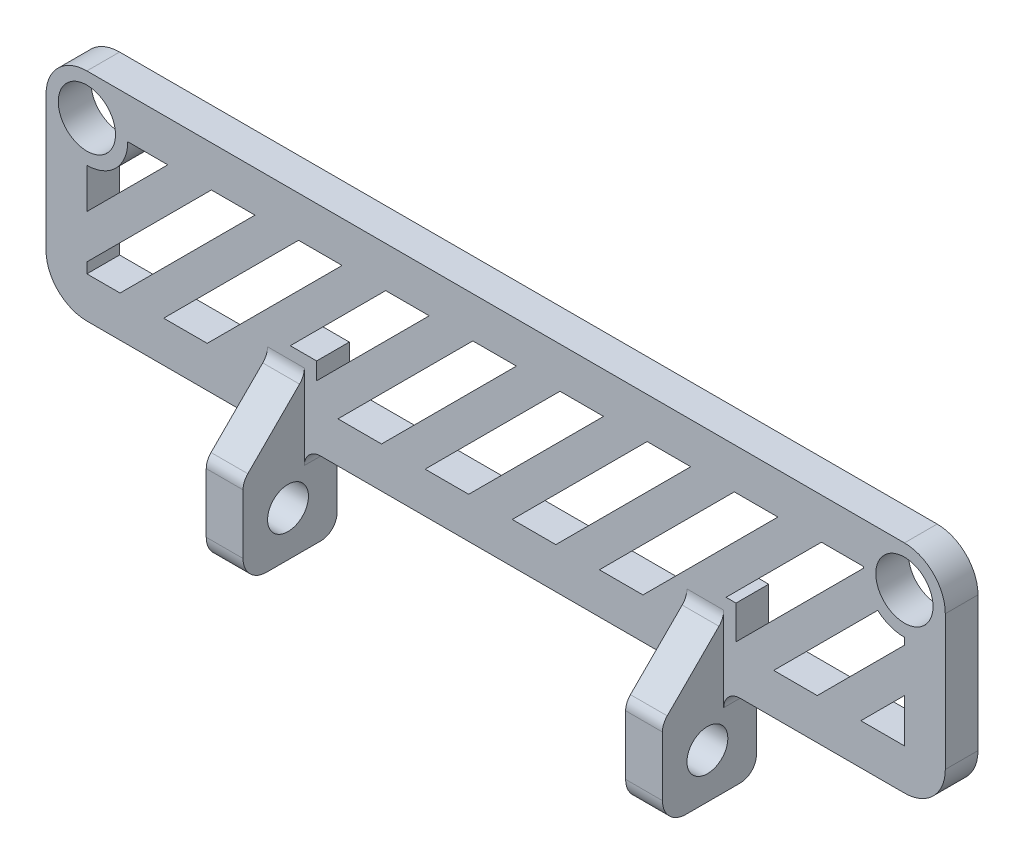
from build123d import *

# Parameters (mm, degrees)
ESQUISSE1_R             = 1.75
BOSS_EXTRU_1_DEPTH      = 2
ESQUISSE1_3_W           = 2.25
ESQUISSE1_3_H           = 5.5
BOSS_EXTRU_3_DEPTH      = 5.75
ENL_V_MAT_EXTRU_4_REACH = 44.884
ESQUISSE2_W             = 5.75
ESQUISSE2_H             = 5.5
ENL_V_MAT_EXTRU_5_REACH = 44.884
ESQUISSE2_5_R           = 1.25
NERVURE1_REACH          = 44.884
ESQUISSE4_WALL_W        = 93.071724536
ESQUISSE4_WALL_H        = 2.25
CONG_1_R                = 1.45
CONG_2_R                = 1
ENL_V_MAT_EXTRU_6_REACH = 31.295
CONG_4_R                = 2.5


with BuildPart() as part:
    # Esquisse1 → Boss.-Extru.1 (new body)
    with BuildSketch(Plane.XY):
        Polygon((27.5, 9.375), (-27.5, 9.375), (-27.5, -9.375), (-13.95, -9.375), (-13.95, -3.875), (-11.7, -3.875), (11.7, -3.875), (13.95, -3.875), (13.95, -9.375), (27.5, -9.375), align=None)
        with Locations((-25, 6.875)):
            Circle(ESQUISSE1_R, mode=Mode.SUBTRACT)
        with Locations((25, 6.875)):
            Circle(ESQUISSE1_R, mode=Mode.SUBTRACT)
    extrude(amount=BOSS_EXTRU_1_DEPTH)

    # Esquisse1_3 → Boss.-Extru.3 (add)
    with BuildSketch(Plane.XY):
        with Locations((-12.825, -6.625)):
            Rectangle(ESQUISSE1_3_W, ESQUISSE1_3_H)
        with Locations((12.825, -6.625)):
            Rectangle(ESQUISSE1_3_W, ESQUISSE1_3_H)
    extrude(amount=BOSS_EXTRU_3_DEPTH)

    # Esquisse2 → Enl_v. mat.-Extru.4 (cut, up to next)
    with BuildSketch(Plane(origin=(13.95, 0, 0), x_dir=(0, 0, -1), z_dir=(1, 0, 0)), mode=Mode.PRIVATE) as enl_v_mat_extru_4_sk1:
        with Locations((-2.875, -6.625)):
            Rectangle(ESQUISSE2_W, ESQUISSE2_H)
    enl_v_mat_extru_4_tool1 = extrude(enl_v_mat_extru_4_sk1.sketch, amount=ENL_V_MAT_EXTRU_4_REACH, mode=Mode.PRIVATE) & part.part
    enl_v_mat_extru_4 = enl_v_mat_extru_4_tool1.solids().sort_by_distance((13.95, -6.625, 2.875))[0]
    add(enl_v_mat_extru_4, mode=Mode.SUBTRACT)

    # Esquisse2_5 → Enl_v. mat.-Extru.5 (cut, up to next)
    with BuildSketch(Plane(origin=(13.95, 0, 0), x_dir=(0, 0, -1), z_dir=(1, 0, 0)), mode=Mode.PRIVATE) as enl_v_mat_extru_5_sk1:
        with Locations((-3, -6.625)):
            Circle(ESQUISSE2_5_R)
    enl_v_mat_extru_5_tool1 = extrude(enl_v_mat_extru_5_sk1.sketch, amount=-ENL_V_MAT_EXTRU_5_REACH, mode=Mode.PRIVATE) & part.part
    enl_v_mat_extru_5 = enl_v_mat_extru_5_tool1.solids().sort_by_distance((13.95, -6.625, 3))[0]
    add(enl_v_mat_extru_5, mode=Mode.SUBTRACT)

    # Esquisse4 wall → Nervure1 (add, up to next)
    with BuildSketch(Plane(origin=(13.95, -2, 3.875), x_dir=(0, 0.707106781187, -0.707106781187), z_dir=(0, 0.707106781187, 0.707106781187)), mode=Mode.PRIVATE) as nervure1_sk1:
        with Locations((0, 1.125)):
            Rectangle(ESQUISSE4_WALL_W, ESQUISSE4_WALL_H)
    nervure1_tool1 = extrude(nervure1_sk1.sketch, amount=-NERVURE1_REACH, mode=Mode.PRIVATE) - part.part
    nervure1 = nervure1_tool1.solids().sort_by_distance((13.95, -2, 3.875))[0]
    add(nervure1)

    # Sym_trie2: Enl_v. mat.-Extru.4, Enl_v. mat.-Extru.5, Nervure1 across plane
    add(enl_v_mat_extru_4.mirror(Plane(origin=(0, 0, 0), x_dir=(0, 0, 1), z_dir=(1, 0, 0))), mode=Mode.SUBTRACT)
    add(enl_v_mat_extru_5.mirror(Plane(origin=(0, 0, 0), x_dir=(0, 0, 1), z_dir=(1, 0, 0))), mode=Mode.SUBTRACT)
    add(nervure1.mirror(Plane(origin=(0, 0, 0), x_dir=(0, 0, 1), z_dir=(1, 0, 0))))

    # Cong_1
    cong_1_edges = [part.edges().sort_by_distance(p)[0] for p in [
        (12.825, -9.375, 5.75),
        (-12.825, -9.375, 5.75),
    ]]
    fillet(cong_1_edges, radius=CONG_1_R)

    # Cong_2
    cong_2_edges = [part.edges().sort_by_distance(p)[0] for p in [
        (12.825, -0.125, 2),
        (12.825, -3.875, 5.75),
        (13.95, -3.875, 1),
        (11.7, -3.875, 1),
        (12.825, -9.375, 0),
        (-12.825, -9.375, 0),
        (-13.95, -3.875, 1),
        (-11.7, -3.875, 1),
        (-12.825, -0.125, 2),
        (-12.825, -3.875, 5.75),
    ]]
    fillet(cong_2_edges, radius=CONG_2_R)

    # Esquisse5 → Enl_v. mat.-Extru.6 (cut, up to next)
    with BuildSketch(Plane.XY.offset(2), mode=Mode.PRIVATE) as enl_v_mat_extru_6_sk1:
        with BuildLine():
            Line((-20.050252532, 6.875), (-22.5, 6.875))
            ThreePointArc((-22.5, 6.875), (-23.232233047, 5.107233047), (-25, 4.375))
            Line((-25, 4.375), (-25, 1.925252532))
            Line((-25, 1.925252532), (-20.050252532, 6.875))
        make_face()
    enl_v_mat_extru_6_tool1 = extrude(enl_v_mat_extru_6_sk1.sketch, amount=-ENL_V_MAT_EXTRU_6_REACH, mode=Mode.PRIVATE) & part.part
    # Esquisse5 → Enl_v. mat.-Extru.6 (cut, up to next)
    with BuildSketch(Plane.XY.offset(2), mode=Mode.PRIVATE) as enl_v_mat_extru_6_sk2:
        Polygon((-14.720227279, 6.875), (-17.385239905, 6.875), (-25, -0.739760095), (-25, -1.375), (-22.970227279, -1.375), align=None)
    enl_v_mat_extru_6_tool2 = extrude(enl_v_mat_extru_6_sk2.sketch, amount=-ENL_V_MAT_EXTRU_6_REACH, mode=Mode.PRIVATE) & part.part
    # Esquisse5 → Enl_v. mat.-Extru.6 (cut, up to next)
    with BuildSketch(Plane.XY.offset(2), mode=Mode.PRIVATE) as enl_v_mat_extru_6_sk3:
        Polygon((-9.390202025, 6.875), (-12.055214652, 6.875), (-20.305214652, -1.375), (-17.640202025, -1.375), align=None)
    enl_v_mat_extru_6_tool3 = extrude(enl_v_mat_extru_6_sk3.sketch, amount=-ENL_V_MAT_EXTRU_6_REACH, mode=Mode.PRIVATE) & part.part
    # Esquisse5 → Enl_v. mat.-Extru.6 (cut, up to next)
    with BuildSketch(Plane.XY.offset(2), mode=Mode.PRIVATE) as enl_v_mat_extru_6_sk4:
        Polygon((-4.060176772, 6.875), (-6.725189399, 6.875), (-12.560975836, 1.039213562), (-10.95, 1.039213562), (-10.95, -0.014823228), align=None)
    enl_v_mat_extru_6_tool4 = extrude(enl_v_mat_extru_6_sk4.sketch, amount=-ENL_V_MAT_EXTRU_6_REACH, mode=Mode.PRIVATE) & part.part
    # Esquisse5 → Enl_v. mat.-Extru.6 (cut, up to next)
    with BuildSketch(Plane.XY.offset(2), mode=Mode.PRIVATE) as enl_v_mat_extru_6_sk5:
        Polygon((1.269848481, 6.875), (-1.395164146, 6.875), (-9.645164146, -1.375), (-6.980151519, -1.375), align=None)
    enl_v_mat_extru_6_tool5 = extrude(enl_v_mat_extru_6_sk5.sketch, amount=-ENL_V_MAT_EXTRU_6_REACH, mode=Mode.PRIVATE) & part.part
    # Esquisse5 → Enl_v. mat.-Extru.6 (cut, up to next)
    with BuildSketch(Plane.XY.offset(2), mode=Mode.PRIVATE) as enl_v_mat_extru_6_sk6:
        Polygon((6.599873734, 6.875), (3.934861108, 6.875), (-4.315138892, -1.375), (-1.650126266, -1.375), align=None)
    enl_v_mat_extru_6_tool6 = extrude(enl_v_mat_extru_6_sk6.sketch, amount=-ENL_V_MAT_EXTRU_6_REACH, mode=Mode.PRIVATE) & part.part
    # Esquisse5 → Enl_v. mat.-Extru.6 (cut, up to next)
    with BuildSketch(Plane.XY.offset(2), mode=Mode.PRIVATE) as enl_v_mat_extru_6_sk7:
        Polygon((11.929898987, 6.875), (9.264886361, 6.875), (1.014886361, -1.375), (3.679898987, -1.375), align=None)
    enl_v_mat_extru_6_tool7 = extrude(enl_v_mat_extru_6_sk7.sketch, amount=-ENL_V_MAT_EXTRU_6_REACH, mode=Mode.PRIVATE) & part.part
    # Esquisse5 → Enl_v. mat.-Extru.6 (cut, up to next)
    with BuildSketch(Plane.XY.offset(2), mode=Mode.PRIVATE) as enl_v_mat_extru_6_sk8:
        Polygon((17.25992424, 6.875), (14.594911614, 6.875), (6.344911614, -1.375), (9.00992424, -1.375), align=None)
    enl_v_mat_extru_6_tool8 = extrude(enl_v_mat_extru_6_sk8.sketch, amount=-ENL_V_MAT_EXTRU_6_REACH, mode=Mode.PRIVATE) & part.part
    # Esquisse5 → Enl_v. mat.-Extru.6 (cut, up to next)
    with BuildSketch(Plane.XY.offset(2), mode=Mode.PRIVATE) as enl_v_mat_extru_6_sk9:
        with BuildLine():
            Line((22.5, 6.875), (19.924936867, 6.875))
            Line((19.924936867, 6.875), (14.089150429, 1.039213562))
            Line((14.089150429, 1.039213562), (14.7, 1.039213562))
            Line((14.7, 1.039213562), (14.7, -1.014949494))
            Line((14.7, -1.014949494), (22.501562926, 6.786613432))
            ThreePointArc((22.501562926, 6.786613432), (22.500390762, 6.830799807), (22.5, 6.875))
        make_face()
    enl_v_mat_extru_6_tool9 = extrude(enl_v_mat_extru_6_sk9.sketch, amount=-ENL_V_MAT_EXTRU_6_REACH, mode=Mode.PRIVATE) & part.part
    # Esquisse5 → Enl_v. mat.-Extru.6 (cut, up to next)
    with BuildSketch(Plane.XY.offset(2), mode=Mode.PRIVATE) as enl_v_mat_extru_6_sk10:
        with BuildLine():
            ThreePointArc((25, 4.375), (24.127249624, 4.532286449), (23.364316695, 4.984354575))
            Line((23.364316695, 4.984354575), (17.00496212, -1.375))
            Line((17.00496212, -1.375), (19.669974747, -1.375))
            Line((19.669974747, -1.375), (25, 3.955025253))
            Line((25, 3.955025253), (25, 4.375))
        make_face()
    enl_v_mat_extru_6_tool10 = extrude(enl_v_mat_extru_6_sk10.sketch, amount=-ENL_V_MAT_EXTRU_6_REACH, mode=Mode.PRIVATE) & part.part
    # Esquisse5 → Enl_v. mat.-Extru.6 (cut, up to next)
    with BuildSketch(Plane.XY.offset(2), mode=Mode.PRIVATE) as enl_v_mat_extru_6_sk11:
        Polygon((25, -1.375), (25, 1.290012627), (22.334987373, -1.375), align=None)
    enl_v_mat_extru_6_tool11 = extrude(enl_v_mat_extru_6_sk11.sketch, amount=-ENL_V_MAT_EXTRU_6_REACH, mode=Mode.PRIVATE) & part.part
    add(enl_v_mat_extru_6_tool1.solids().sort_by_distance((-22.956327, 4.831327, 2))[0], mode=Mode.SUBTRACT)
    add(enl_v_mat_extru_6_tool2.solids().sort_by_distance((-20.131109, 2.786244, 2))[0], mode=Mode.SUBTRACT)
    add(enl_v_mat_extru_6_tool3.solids().sort_by_distance((-14.847708, 2.75, 2))[0], mode=Mode.SUBTRACT)
    add(enl_v_mat_extru_6_tool4.solids().sort_by_distance((-8.389483, 3.844364, 2))[0], mode=Mode.SUBTRACT)
    add(enl_v_mat_extru_6_tool5.solids().sort_by_distance((-4.187658, 2.75, 2))[0], mode=Mode.SUBTRACT)
    add(enl_v_mat_extru_6_tool6.solids().sort_by_distance((1.142367, 2.75, 2))[0], mode=Mode.SUBTRACT)
    add(enl_v_mat_extru_6_tool7.solids().sort_by_distance((6.472393, 2.75, 2))[0], mode=Mode.SUBTRACT)
    add(enl_v_mat_extru_6_tool8.solids().sort_by_distance((11.802418, 2.75, 2))[0], mode=Mode.SUBTRACT)
    add(enl_v_mat_extru_6_tool9.solids().sort_by_distance((17.98556, 3.526015, 2))[0], mode=Mode.SUBTRACT)
    add(enl_v_mat_extru_6_tool10.solids().sort_by_distance((21.26436, 1.581944, 2))[0], mode=Mode.SUBTRACT)
    add(enl_v_mat_extru_6_tool11.solids().sort_by_distance((24.111662, -0.486662, 2))[0], mode=Mode.SUBTRACT)

    # Cong_4
    cong_4_edges = [part.edges().sort_by_distance(p)[0] for p in [
        (-27.5, -3.875, 1),
        (-27.5, 9.375, 1),
        (27.5, 9.375, 1),
        (27.5, -3.875, 1),
    ]]
    fillet(cong_4_edges, radius=CONG_4_R)


solid = part.part
